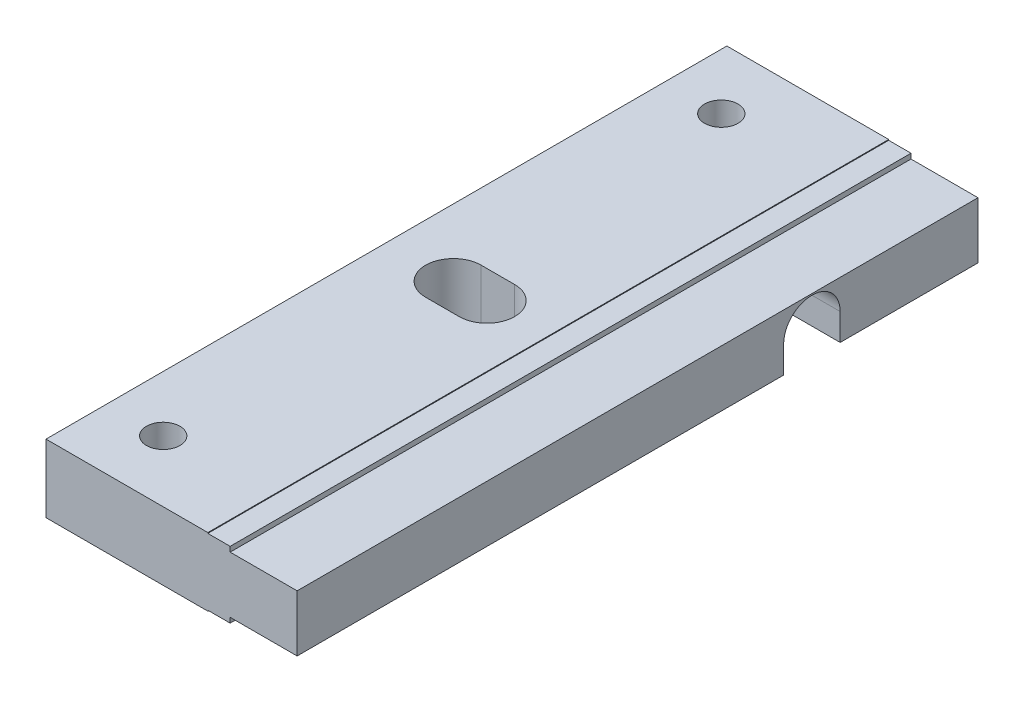
from build123d import *

# Parameters (mm, degrees)
SKETCH1_W           = 61
SKETCH1_H           = 6.1
BOSS_EXTRUDE1_DEPTH = 22.5
SKETCH2_OUTSIDE_W   = 76.06
SKETCH2_OUTSIDE_H   = 21.16
SKETCH2_OUTSIDE_W_2 = 61
SKETCH2_OUTSIDE_H_2 = 5.1952
CUT_EXTRUDE1_DEPTH  = 6
CUT_EXTRUDE3_DEPTH  = 23.5
CUT_EXTRUDE4_DEPTH  = 7.1
SKETCH7_R           = 1.5
CUT_EXTRUDE5_DEPTH  = 7.1
SKETCH8_W           = 2
SKETCH8_H           = 0.06858
SKETCH8_W_2         = 6
CUT_EXTRUDE6_DEPTH  = 62


with BuildPart() as part:
    # Sketch1 → Boss-Extrude1 (new body)
    with BuildSketch(Plane(origin=(0, 0, 0), x_dir=(0, 0, -1), z_dir=(1, 0, 0))):
        with Locations((30.5, 0)):
            Rectangle(SKETCH1_W, SKETCH1_H)
    extrude(amount=BOSS_EXTRUDE1_DEPTH)

    # Sketch2 outside → Cut-Extrude1 (cut)
    with BuildSketch(Plane(origin=(22.5, 0, 0), x_dir=(0, 0, -1), z_dir=(1, 0, 0))):
        with Locations((30.5, 0)):
            Rectangle(SKETCH2_OUTSIDE_W, SKETCH2_OUTSIDE_H)
        with Locations((30.5, 0)):
            Rectangle(SKETCH2_OUTSIDE_W_2, SKETCH2_OUTSIDE_H_2, mode=Mode.SUBTRACT)
    extrude(amount=-CUT_EXTRUDE1_DEPTH, mode=Mode.SUBTRACT)

    # Sketch5 → Cut-Extrude3 (cut, through all)
    with BuildSketch(Plane.ZY):
        with BuildLine():
            Line((-43.5866, -0.1278), (-43.5866, -3.05))
            Line((-43.5866, -3.05), (-48.6514, -3.05))
            Line((-48.6514, -3.05), (-48.6514, -0.1278))
            ThreePointArc((-48.6514, -0.1278), (-46.119, 2.4046), (-43.5866, -0.1278))
        make_face()
    extrude(amount=-CUT_EXTRUDE3_DEPTH, mode=Mode.SUBTRACT)

    # Sketch6 → Cut-Extrude4 (cut, through all)
    with BuildSketch(Plane(origin=(0, 3.05, 0), x_dir=(1, 0, 0), z_dir=(0, 1, 0))):
        with BuildLine():
            Line((6, 32.9892), (9, 32.9892))
            ThreePointArc((9, 32.9892), (11.4892, 30.5), (9, 28.0108))
            Line((9, 28.0108), (6, 28.0108))
            ThreePointArc((6, 28.0108), (3.5108, 30.5), (6, 32.9892))
        make_face()
    extrude(amount=-CUT_EXTRUDE4_DEPTH, mode=Mode.SUBTRACT)

    # Sketch7 → Cut-Extrude5 (cut, through all)
    with BuildSketch(Plane(origin=(0, 3.05, 0), x_dir=(1, 0, 0), z_dir=(0, 1, 0))):
        with Locations(Location((5, 55.5, 0), (0, 0, 270))):  # turned: the seam where the file's is
            Circle(SKETCH7_R)
        with Locations(Location((5, 5.5, 0), (0, 0, 270))):  # turned: the seam where the file's is
            Circle(SKETCH7_R)
    extrude(amount=-CUT_EXTRUDE5_DEPTH, mode=Mode.SUBTRACT)

    # Sketch8 → Cut-Extrude6 (cut, through all)
    with BuildSketch(Plane.XY):
        with Locations((15.5, -3.01571)):
            Rectangle(SKETCH8_W, SKETCH8_H)
        with Locations((19.5, -2.56331)):
            Rectangle(SKETCH8_W_2, SKETCH8_H)
        with Locations((19.5, 2.56331)):
            Rectangle(SKETCH8_W_2, SKETCH8_H)
        with Locations((15.5, 3.01571)):
            Rectangle(SKETCH8_W, SKETCH8_H)
    extrude(amount=-CUT_EXTRUDE6_DEPTH, mode=Mode.SUBTRACT)


solid = part.part
